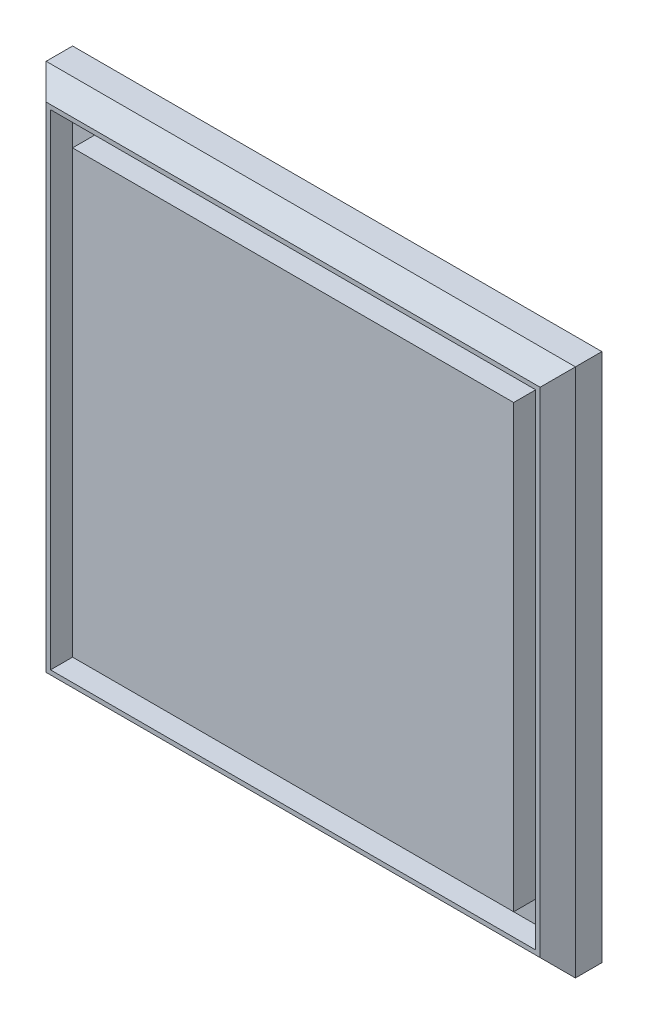
from build123d import *

# Parameters (mm, degrees)
SKETCH_1_W          = 240
SKETCH_1_H          = 240
EXTRUDE_1_DEPTH     = 20
CHAMFER_1_SIZE      = 8
SKETCH_2_W          = 220
SKETCH_2_H          = 220
SKETCH_2_W_2        = 200
SKETCH_2_H_2        = 200
CUT_EXTRUDE_1_DEPTH = 10


with BuildPart() as part:
    # Эскиз1 → Бобышка-Вытянуть1 (new body)
    with BuildSketch(Plane.XY):
        Rectangle(SKETCH_1_W, SKETCH_1_H)
    extrude(amount=EXTRUDE_1_DEPTH)

    # Фаска1
    chamfer_1_edges = [part.edges().sort_by_distance(p)[0] for p in [
        (0, -120, 20),
        (-120, 0, 20),
        (0, 120, 20),
        (120, 0, 20),
    ]]
    chamfer(chamfer_1_edges, length=CHAMFER_1_SIZE)

    # Эскиз2 → Вырез-Вытянуть1 (cut)
    with BuildSketch(Plane.XY.offset(20)):
        Rectangle(SKETCH_2_W, SKETCH_2_H)
        Rectangle(SKETCH_2_W_2, SKETCH_2_H_2, mode=Mode.SUBTRACT)
    extrude(amount=-CUT_EXTRUDE_1_DEPTH, mode=Mode.SUBTRACT)


solid = part.part
